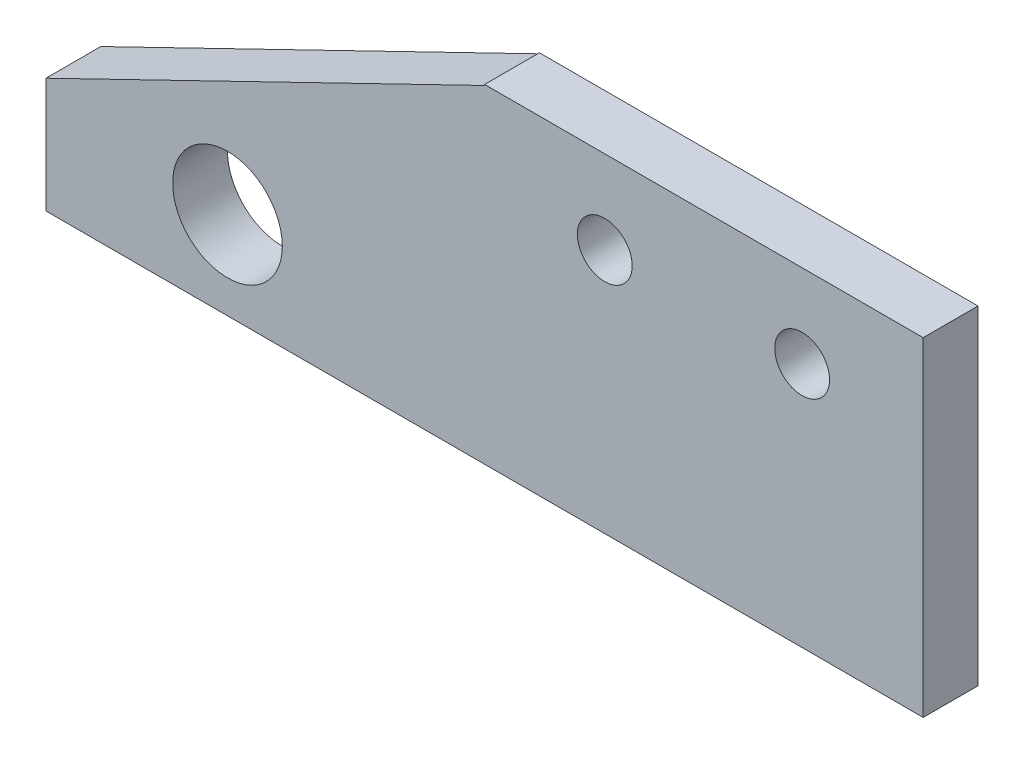
from build123d import *

# Parameters (mm, degrees)
SKETCH4_R           = 1.5875
SKETCH4_R_2         = 3.175
BOSS_EXTRUDE1_DEPTH = 3.175


with BuildPart() as part:
    # Sketch4 → Boss-Extrude1 (new body)
    with BuildSketch(Plane.XY):
        Polygon((12.7, 9.525), (-12.7, 9.525), (-12.7, 9.47226002), (-38.1, -2.862183506), (-38.1, -9.525), (12.7, -9.525), align=None)
        with Locations((-5.7404, 4.699)):
            Circle(SKETCH4_R, mode=Mode.SUBTRACT)
        with Locations((5.6896, 4.699)):
            Circle(SKETCH4_R, mode=Mode.SUBTRACT)
        with Locations((-27.589559724, -4.445)):
            Circle(SKETCH4_R_2, mode=Mode.SUBTRACT)
    extrude(amount=BOSS_EXTRUDE1_DEPTH)


solid = part.part
